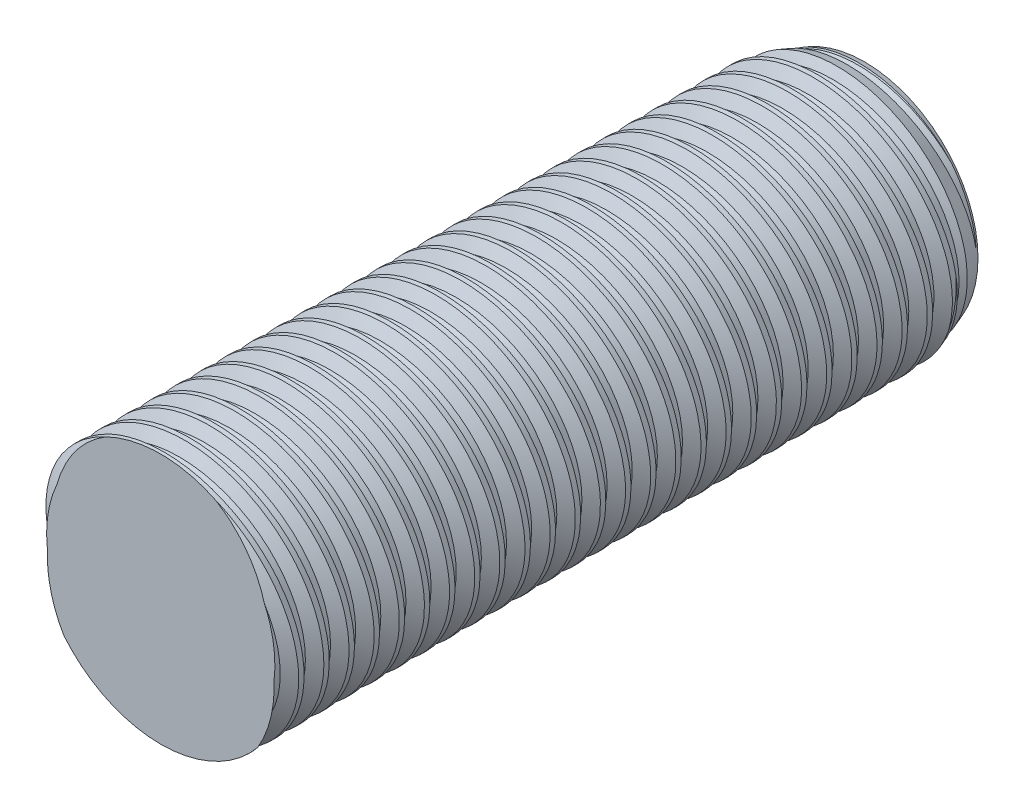
from build123d import *

# Parameters (mm, degrees)
SKETCH1_W       = 35.56
SKETCH1_H       = 6.35
LPATTERN1_COUNT = 28
LPATTERN1_PITCH = 1.27
LPATTERN2_COUNT = 2
LPATTERN2_PITCH = 1.27


with BuildPart() as part:
    # Sketch1 → Revolve1 (revolve)
    with BuildSketch(Plane(origin=(0, 0, 0), x_dir=(0, 0, -1), z_dir=(1, 0, 0))):
        with Locations((17.78, 3.175)):
            Rectangle(SKETCH1_W, SKETCH1_H)
    revolve(axis=Axis((0, 0, 0), (0, 0, 1)))

    # Sketch2 → Cut-Revolve1 (revolve, cut)
    with BuildSketch(Plane(origin=(0, 0, 0), x_dir=(0, 0, -1), z_dir=(1, 0, 0))):
        Polygon((0.157962154, 6.365796215), (1.263697232, 6.476369723), (0.937191466, 5.752882994), (0.621267158, 5.721290563), align=None)
    cut_revolve1 = revolve(axis=Axis((0, -0.135293799, 0), (0, 0.099503719, -0.99503719)), mode=Mode.SUBTRACT)

    # Sketch3 → Cut-Revolve2 (revolve, cut)
    with BuildSketch(Plane(origin=(0, 0, 0), x_dir=(0, 0, -1), z_dir=(1, 0, 0))):
        Polygon((35.56, 5.721290563), (33.832635019, 6.35), (35.56, 6.35), align=None)
    revolve(axis=Axis((0, 0, -33.832635019), (0, 0, 1)), mode=Mode.SUBTRACT)

    # LPattern1: Cut-Revolve1 ×28
    with Locations(*[(0, 0, -i * LPATTERN1_PITCH) for i in range(1, LPATTERN1_COUNT)]):
        add(cut_revolve1, mode=Mode.SUBTRACT)

    # LPattern2: Cut-Revolve1 ×2
    with Locations(*[(0, 0, i * LPATTERN2_PITCH) for i in range(1, LPATTERN2_COUNT)]):
        add(cut_revolve1, mode=Mode.SUBTRACT)


solid = part.part
